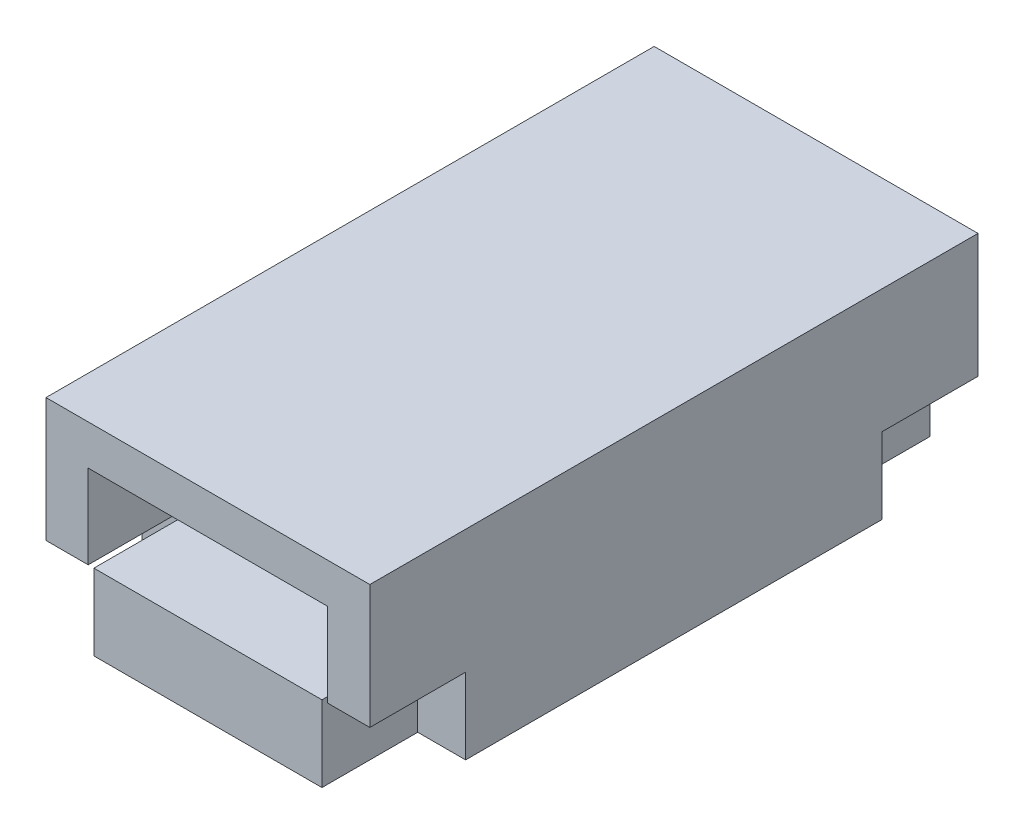
from build123d import *

# Parameters (mm, degrees)
SKETCH1_W           = 13.525
SKETCH1_H           = 7.40621
SKETCH1_W_2         = 10
SKETCH1_H_2         = 3.5
BOSS_EXTRUDE1_DEPTH = 12.7
SKETCH2_W           = 2
SKETCH2_H           = 3.175
CUT_EXTRUDE2_DEPTH  = 4
SKETCH2_4_W         = 13.525
SKETCH2_4_H         = 0.939
BOSS_EXTRUDE2_DEPTH = 12.7


with BuildPart() as part:
    # Sketch1 → Boss-Extrude1 (new, symmetric)
    with BuildSketch(Plane.XY):
        with Locations((0, -1.221895)):
            Rectangle(SKETCH1_W, SKETCH1_H)
        Rectangle(SKETCH1_W_2, SKETCH1_H_2, mode=Mode.SUBTRACT)
    extrude(amount=BOSS_EXTRUDE1_DEPTH, both=True)

    # Sketch2 → Cut-Extrude2 (cut)
    with BuildSketch(Plane.XY.offset(12.7)):
        with Locations((-5.7625, -3.3375)):
            Rectangle(SKETCH2_W, SKETCH2_H)
        with Locations((5.7625, -3.3375)):
            Rectangle(SKETCH2_W, SKETCH2_H)
    cut_extrude2 = extrude(amount=-CUT_EXTRUDE2_DEPTH, mode=Mode.SUBTRACT)

    # Sketch2_4 → Boss-Extrude2 (add)
    with BuildSketch(Plane.XY.offset(12.7)):
        with Locations((0, 2.95071)):
            Rectangle(SKETCH2_4_W, SKETCH2_4_H)
    boss_extrude2 = extrude(amount=-BOSS_EXTRUDE2_DEPTH)

    # Mirror1: Cut-Extrude2, Boss-Extrude2 across plane
    add(cut_extrude2.mirror(Plane.XY), mode=Mode.SUBTRACT)
    add(boss_extrude2.mirror(Plane.XY))


solid = part.part
